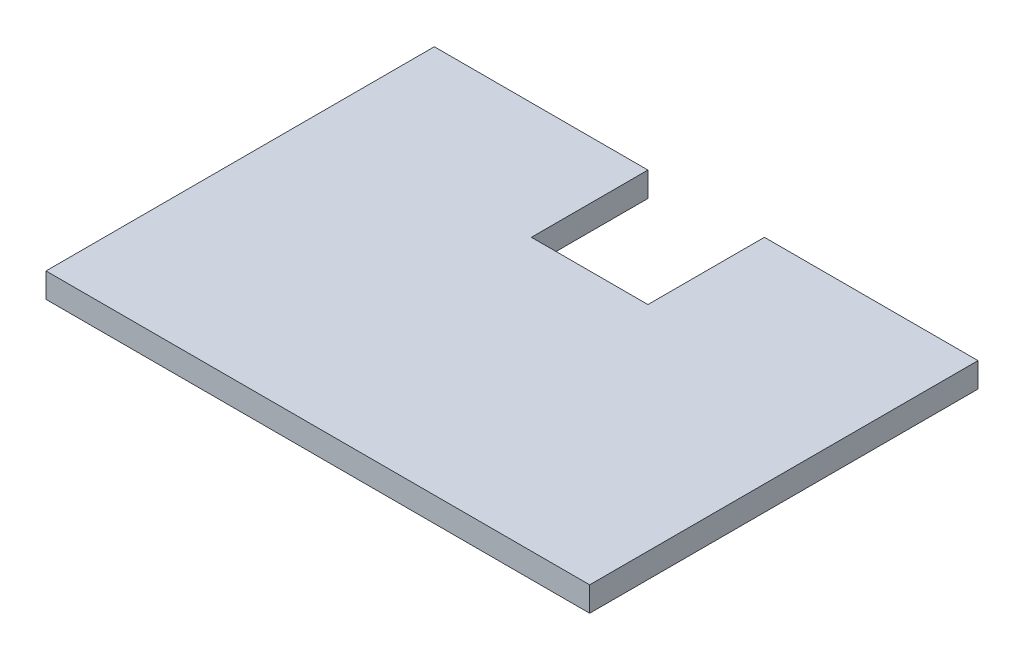
from build123d import *

# Parameters (mm, degrees)
SKETCH1_W           = 70
SKETCH1_H           = 50
BOSS_EXTRUDE1_DEPTH = 3.175
SKETCH2_W           = 15
SKETCH2_H           = 15
CUT_EXTRUDE1_DEPTH  = 4.175


with BuildPart() as part:
    # Sketch1 → Boss-Extrude1 (new body)
    with BuildSketch(Plane(origin=(0, 0, 0), x_dir=(1, 0, 0), z_dir=(0, 1, 0))):
        Rectangle(SKETCH1_W, SKETCH1_H)
    extrude(amount=BOSS_EXTRUDE1_DEPTH)

    # Sketch2 → Cut-Extrude1 (cut, through all)
    with BuildSketch(Plane(origin=(0, 3.175, 0), x_dir=(1, 0, 0), z_dir=(0, 1, 0))):
        with Locations((0, 17.5)):
            Rectangle(SKETCH2_W, SKETCH2_H)
    extrude(amount=-CUT_EXTRUDE1_DEPTH, mode=Mode.SUBTRACT)


solid = part.part
